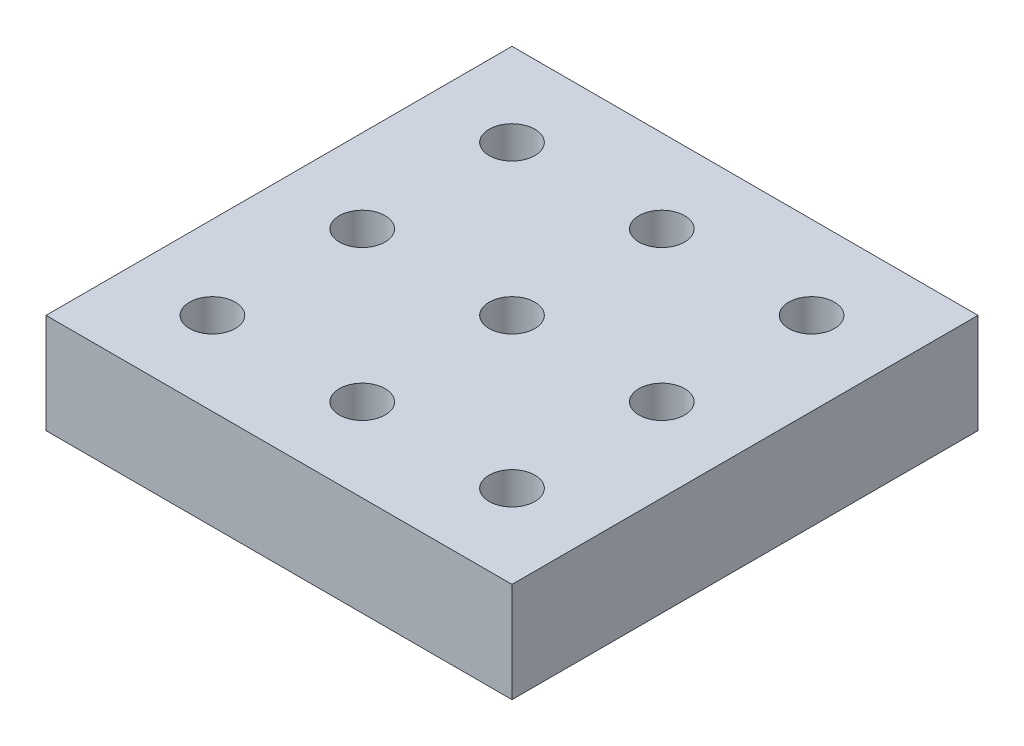
from build123d import *

# Parameters (mm, degrees)
SKETCH1_W           = 56
SKETCH1_H           = 56
SKETCH1_R           = 2.75
BOSS_EXTRUDE2_DEPTH = 12


with BuildPart() as part:
    # Sketch1 → Boss-Extrude2 (new body)
    with BuildSketch(Plane(origin=(0, 0, 0), x_dir=(1, 0, 0), z_dir=(0, 1, 0))):
        with Locations((-24.911392405, 19.293363463)):
            Rectangle(SKETCH1_W, SKETCH1_H)
        with Locations((-42.911392405, 37.293363463)):
            Circle(SKETCH1_R, mode=Mode.SUBTRACT)
        with Locations((-24.911392405, 37.293363463)):
            Circle(SKETCH1_R, mode=Mode.SUBTRACT)
        with Locations((-6.911392405, 37.293363463)):
            Circle(SKETCH1_R, mode=Mode.SUBTRACT)
        with Locations((-24.911392405, 19.293363463)):
            Circle(SKETCH1_R, mode=Mode.SUBTRACT)
        with Locations((-6.911392405, 19.293363463)):
            Circle(SKETCH1_R, mode=Mode.SUBTRACT)
        with Locations((-24.911392405, 1.293363463)):
            Circle(SKETCH1_R, mode=Mode.SUBTRACT)
        with Locations((-6.911392405, 1.293363463)):
            Circle(SKETCH1_R, mode=Mode.SUBTRACT)
        with Locations((-42.911392405, 19.293363463)):
            Circle(SKETCH1_R, mode=Mode.SUBTRACT)
        with Locations((-42.911392405, 1.293363463)):
            Circle(SKETCH1_R, mode=Mode.SUBTRACT)
    extrude(amount=BOSS_EXTRUDE2_DEPTH)


solid = part.part
